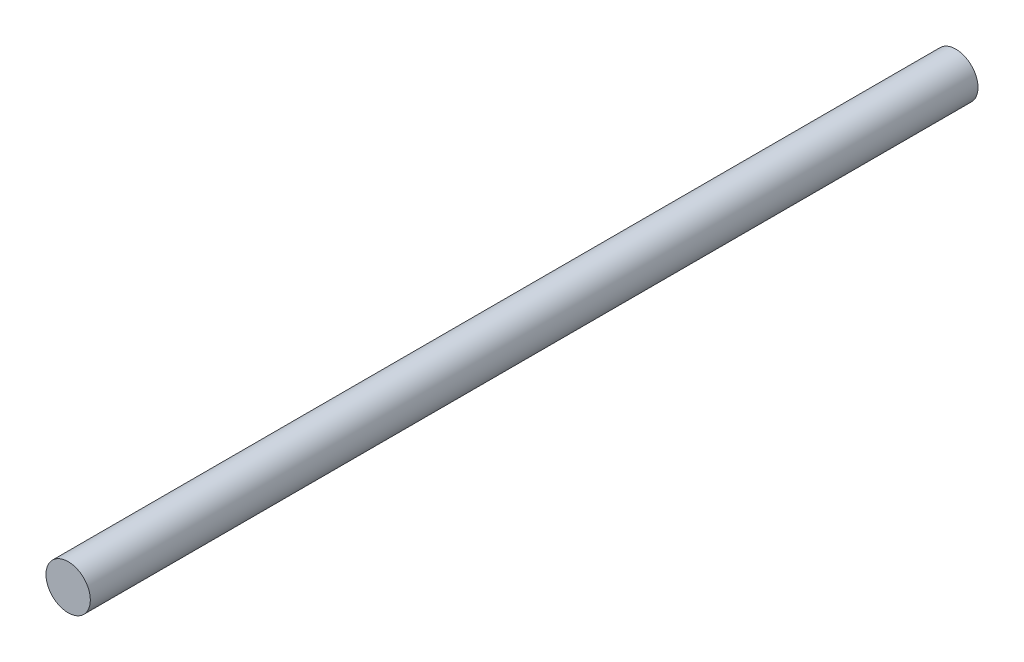
from build123d import *

# Parameters (mm, degrees)
SKETCH1_R           = 10
BOSS_EXTRUDE1_DEPTH = 400


with BuildPart() as part:
    # Sketch1 → Boss-Extrude1 (new body)
    with BuildSketch(Plane.XY):
        Circle(SKETCH1_R)
    extrude(amount=BOSS_EXTRUDE1_DEPTH)


solid = part.part
